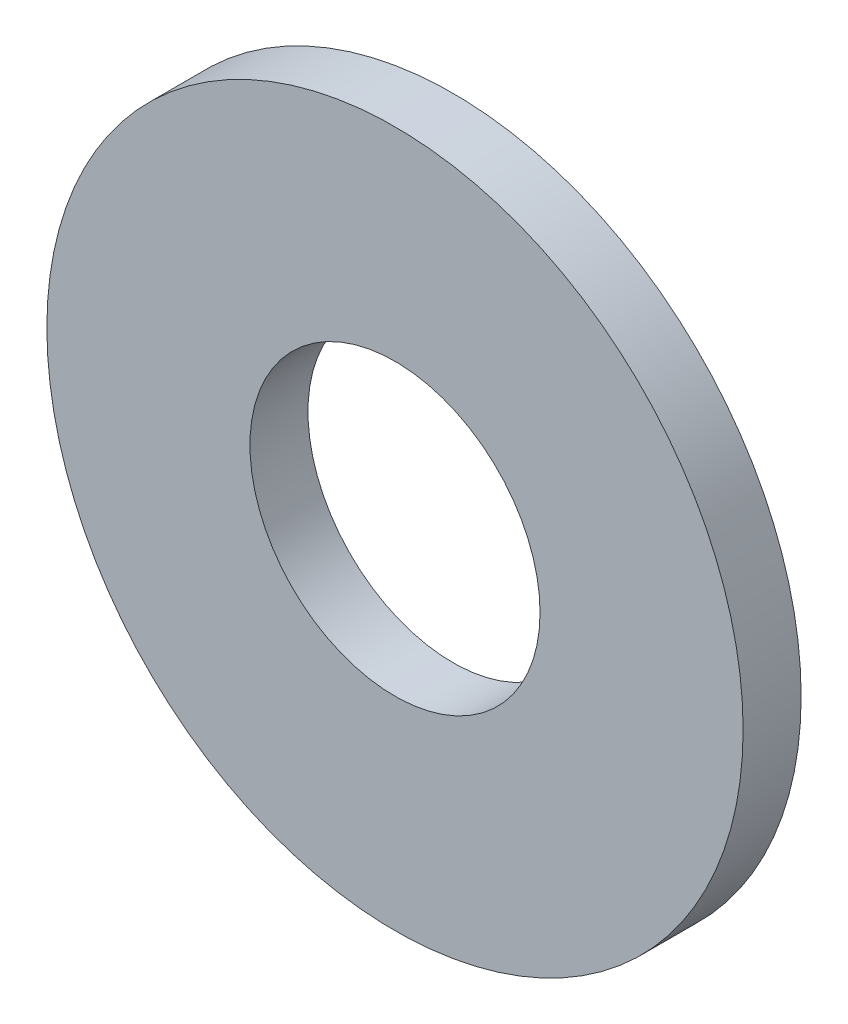
from build123d import *

# Parameters (mm, degrees)
SKETCH1_R           = 6
SKETCH1_R_2         = 2.5
BOSS_EXTRUDE1_DEPTH = 1


with BuildPart() as part:
    # Sketch1 → Boss-Extrude1 (new body)
    with BuildSketch(Plane.XY):
        Circle(SKETCH1_R)
        Circle(SKETCH1_R_2, mode=Mode.SUBTRACT)
    extrude(amount=BOSS_EXTRUDE1_DEPTH)


solid = part.part
